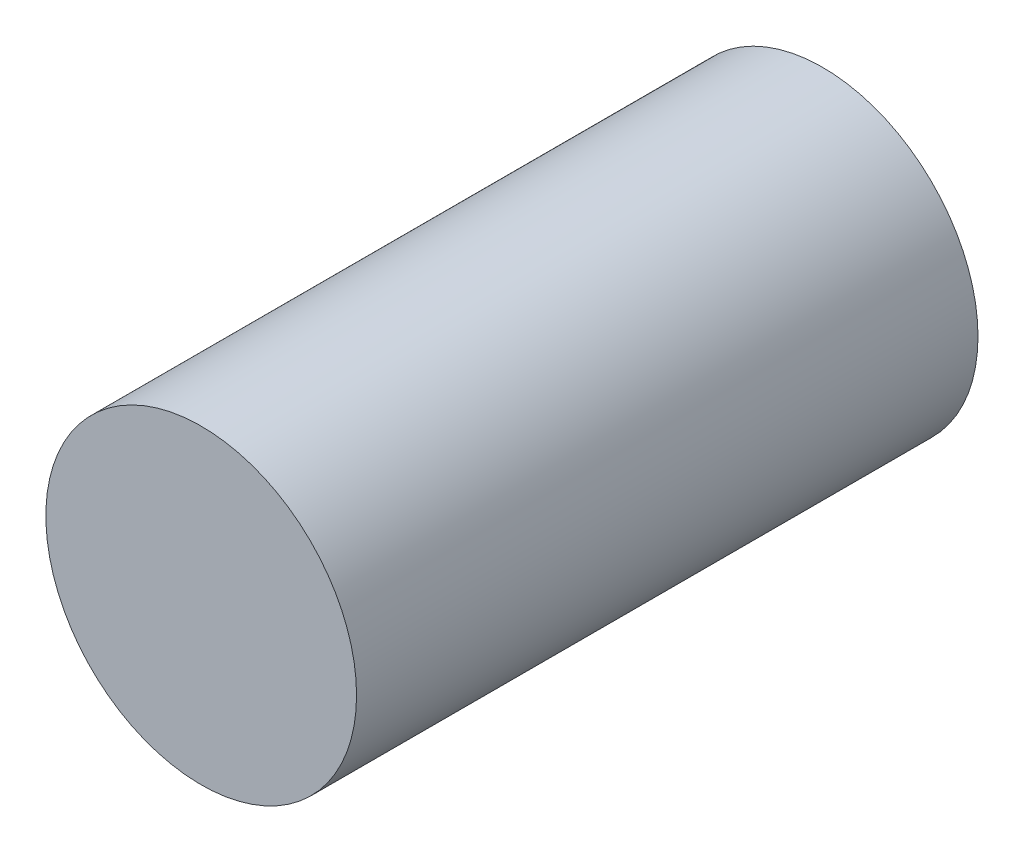
from build123d import *

# Parameters (mm, degrees)
ESQUISSE1_R        = 20
BOSS_EXTRU_1_DEPTH = 80


with BuildPart() as part:
    # Esquisse1 → Boss.-Extru.1 (new body)
    with BuildSketch(Plane.XY):
        Circle(ESQUISSE1_R)
    extrude(amount=BOSS_EXTRU_1_DEPTH)


solid = part.part
